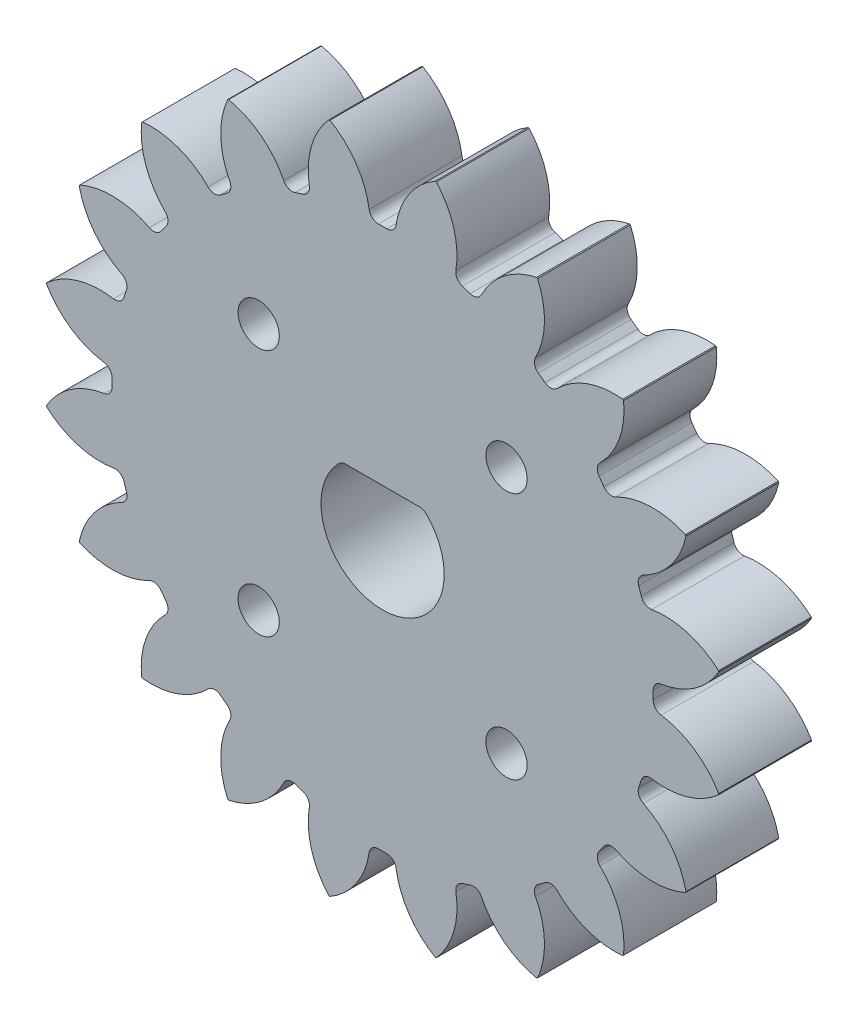
from build123d import *

# Parameters (mm, degrees)
SKETCH1_R                = 33
BOSS_EXTRUDE1_DEPTH      = 9
CUT_EXTRUDE1_START       = -10
CUT_EXTRUDE1_DEPTH       = 11
FILLET1_R                = 0.9
CIRPATTERN3_COUNT        = 20
FILLET1_OF_CIRPATTERN3_R = 0.9
SKETCH4_R                = 2
CUT_EXTRUDE4_DEPTH       = 10.0000001
CUT_EXTRUDE5_DEPTH       = 10.0000001
FILLET2_R                = 1


with BuildPart() as part:
    # Sketch1 → Boss-Extrude1 (new body)
    with BuildSketch(Plane.XY):
        Circle(SKETCH1_R)
    extrude(amount=BOSS_EXTRUDE1_DEPTH)

    # Sketch2 → Cut-Extrude1 (cut)
    with BuildSketch(Plane.XY.offset(9).offset(CUT_EXTRUDE1_START)):
        with BuildLine():
            Line((-145.149685153, 113.520243779), (-5.110395214, 32.60189965))
            ThreePointArc((-5.110395214, 32.60189965), (-2.353772872, 29.907520012), (-1.226544733, 26.221328876))
            ThreePointArc((-1.226544733, 26.221328876), (0, 26.25), (1.226544733, 26.221328876))
            ThreePointArc((1.226544733, 26.221328876), (2.353772872, 29.907520012), (5.110395214, 32.60189965))
            Line((5.110395214, 32.60189965), (145.149685153, 113.520243779))
            Line((145.149685153, 113.520243779), (145.149685153, 436.993773722))
            Line((145.149685153, 436.993773722), (-145.149685153, 436.993773722))
            Line((-145.149685153, 436.993773722), (-145.149685153, 113.520243779))
        make_face()
    cut_extrude1 = extrude(amount=CUT_EXTRUDE1_DEPTH, mode=Mode.SUBTRACT)

    # Fillet1
    fillet1_edges = [part.edges().sort_by_distance(p)[0] for p in [
        (1.226544733, 26.221328876, 4.5),
        (-1.226544733, 26.221328876, 4.5),
    ]]
    fillet(fillet1_edges, radius=FILLET1_R)

    # CirPattern3: Cut-Extrude1 ×20 about axis
    cirpattern3_axis = Axis((0, 0, 0), (0, 0, 1))
    for i in range(1, CIRPATTERN3_COUNT):
        add(cut_extrude1.rotate(cirpattern3_axis, i * 360 / CIRPATTERN3_COUNT), mode=Mode.SUBTRACT)

    # Fillet1 of CirPattern3
    fillet1_of_cirpattern3_edges = [part.edges().sort_by_distance(p)[0] for p in [
        (-6.936322876, 25.31698886, 4.5),
        (-9.269349599, 24.558942526, 4.5),
        (-14.420214875, 21.934445581, 4.5),
        (-16.404805943, 20.49255577, 4.5),
        (-20.49255577, 16.404805943, 4.5),
        (-21.934445581, 14.420214875, 4.5),
        (-24.558942526, 9.269349599, 4.5),
        (-25.31698886, 6.936322876, 4.5),
        (-26.221328876, 1.226544733, 4.5),
        (-26.221328876, -1.226544733, 4.5),
        (-25.31698886, -6.936322876, 4.5),
        (-24.558942526, -9.269349599, 4.5),
        (-21.934445581, -14.420214875, 4.5),
        (-20.49255577, -16.404805943, 4.5),
        (-16.404805943, -20.49255577, 4.5),
        (-14.420214875, -21.934445581, 4.5),
        (-9.269349599, -24.558942526, 4.5),
        (-6.936322876, -25.31698886, 4.5),
        (-1.226544733, -26.221328876, 4.5),
        (1.226544733, -26.221328876, 4.5),
        (6.936322876, -25.31698886, 4.5),
        (9.269349599, -24.558942526, 4.5),
        (14.420214875, -21.934445581, 4.5),
        (16.404805943, -20.49255577, 4.5),
        (20.49255577, -16.404805943, 4.5),
        (21.934445581, -14.420214875, 4.5),
        (24.558942526, -9.269349599, 4.5),
        (25.31698886, -6.936322876, 4.5),
        (26.221328876, -1.226544733, 4.5),
        (26.221328876, 1.226544733, 4.5),
        (25.31698886, 6.936322876, 4.5),
        (24.558942526, 9.269349599, 4.5),
        (21.934445581, 14.420214875, 4.5),
        (20.49255577, 16.404805943, 4.5),
        (16.404805943, 20.49255577, 4.5),
        (14.420214875, 21.934445581, 4.5),
        (9.269349599, 24.558942526, 4.5),
        (6.936322876, 25.31698886, 4.5),
    ]]
    fillet(fillet1_of_cirpattern3_edges, radius=FILLET1_OF_CIRPATTERN3_R)

    # Sketch4 → Cut-Extrude4 (cut, through all)
    with BuildSketch(Plane.XY.offset(9)):
        with Locations((-12.02081528, 12.02081528)):
            Circle(SKETCH4_R)
        with Locations((12.02081528, 12.02081528)):
            Circle(SKETCH4_R)
        with Locations((12.02081528, -12.02081528)):
            Circle(SKETCH4_R)
        with Locations((-12.02081528, -12.02081528)):
            Circle(SKETCH4_R)
    extrude(amount=-CUT_EXTRUDE4_DEPTH, mode=Mode.SUBTRACT)

    # Sketch3 → Cut-Extrude5 (cut, through all)
    with BuildSketch(Plane.XY.offset(9)):
        with BuildLine():
            Line((3.959166579, 4.475), (-3.959166579, 4.475))
            ThreePointArc((-3.959166579, 4.475), (-2.454037967, -5.447781443), (5.975, 0))
            ThreePointArc((5.975, 0), (5.447781443, 2.454037967), (3.959166579, 4.475))
        make_face()
    extrude(amount=-CUT_EXTRUDE5_DEPTH, mode=Mode.SUBTRACT)

    # Fillet2
    fillet2_edges = [part.edges().sort_by_distance(p)[0] for p in [
        (-3.959166579, 4.475, 4.5),
        (3.959166579, 4.475, 4.5),
    ]]
    fillet(fillet2_edges, radius=FILLET2_R)


solid = part.part
